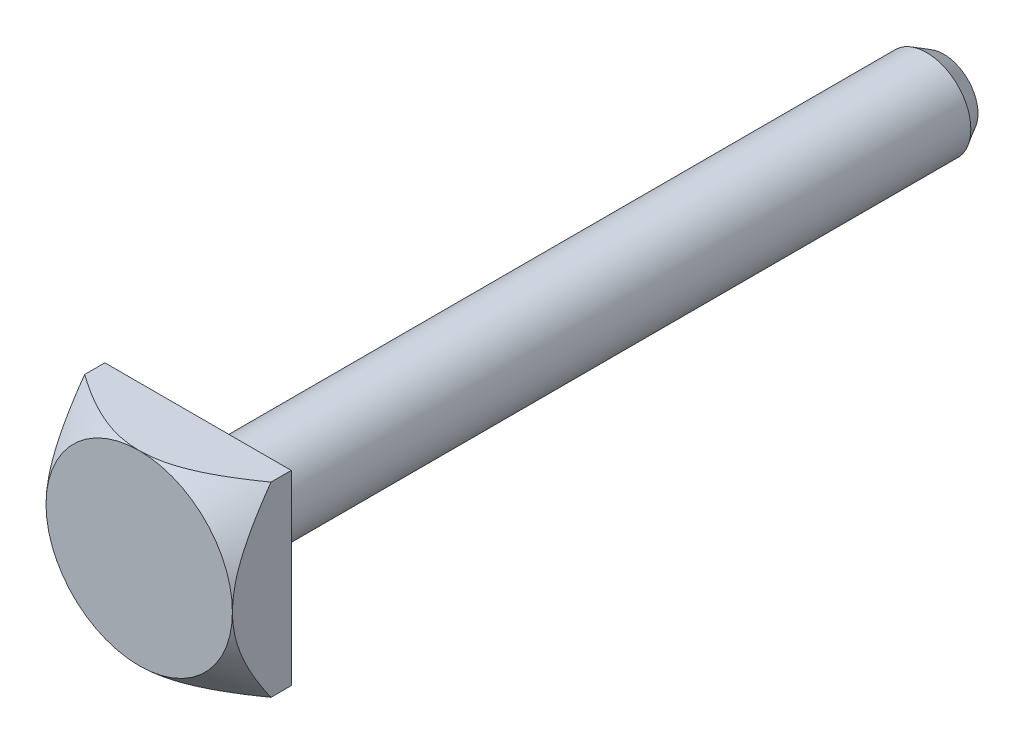
from build123d import *

# Parameters (mm, degrees)
SKETCH2_R           = 4.5
BOSS_EXTRUDE1_DEPTH = 76
SKETCH3_W           = 19
SKETCH3_H           = 19
BOSS_EXTRUDE2_DEPTH = 6
CHAMFER1_SIZE       = 1
CHAMFER1_SIZE2      = 1.732050808
SKETCH4_OUTSIDE_W   = 50.258
SKETCH4_OUTSIDE_H   = 50.258
SKETCH4_OUTSIDE_R   = 9.5
CUT_EXTRUDE1_DEPTH  = 6
CUT_EXTRUDE1_DRAFT  = -45


with BuildPart() as part:
    # Sketch2 → Boss-Extrude1 (new body)
    with BuildSketch(Plane.XY):
        Circle(SKETCH2_R)
    extrude(amount=BOSS_EXTRUDE1_DEPTH)

    # Sketch3 → Boss-Extrude2 (add)
    with BuildSketch(Plane.XY.offset(76)):
        Rectangle(SKETCH3_W, SKETCH3_H)
    extrude(amount=BOSS_EXTRUDE2_DEPTH)

    # Chamfer1
    chamfer1_edges = [part.edges().sort_by_distance(p)[0] for p in [
        (-4.5, 0, 0),
    ]]
    chamfer1_side = [part.faces().sort_by_distance(p)[0] for p in [
        (0, 0, 0),
    ]]
    chamfer(chamfer1_edges, length=CHAMFER1_SIZE, length2=CHAMFER1_SIZE2, reference=chamfer1_side[0])


with BuildPart() as cut_extrude1_tool:
    # Sketch4 outside → Cut-Extrude1 (with draft: the straight prism first)
    with BuildSketch(Plane.XY.offset(82)):
        Rectangle(SKETCH4_OUTSIDE_W, SKETCH4_OUTSIDE_H)
        Circle(SKETCH4_OUTSIDE_R, mode=Mode.SUBTRACT)
    extrude(amount=-CUT_EXTRUDE1_DEPTH)
    # Cut-Extrude1: the draft: its side faces are tilted about the plane it starts from
    cut_extrude1_sides = [cut_extrude1_tool.faces().sort_by_distance(p)[0] for p in [
        (0, -25.129, 79),
        (25.129, 0, 79),
        (0, 25.129, 79),
        (-25.129, 0, 79),
        (-9.5, 0, 79),
    ]]
    draft(cut_extrude1_sides, Plane.XY.offset(82), CUT_EXTRUDE1_DRAFT)


with BuildPart() as part_1:
    add(part.part)

    # Cut-Extrude1: cut by cut_extrude1_tool
    add(cut_extrude1_tool.part, mode=Mode.SUBTRACT)


solid = part_1.part
